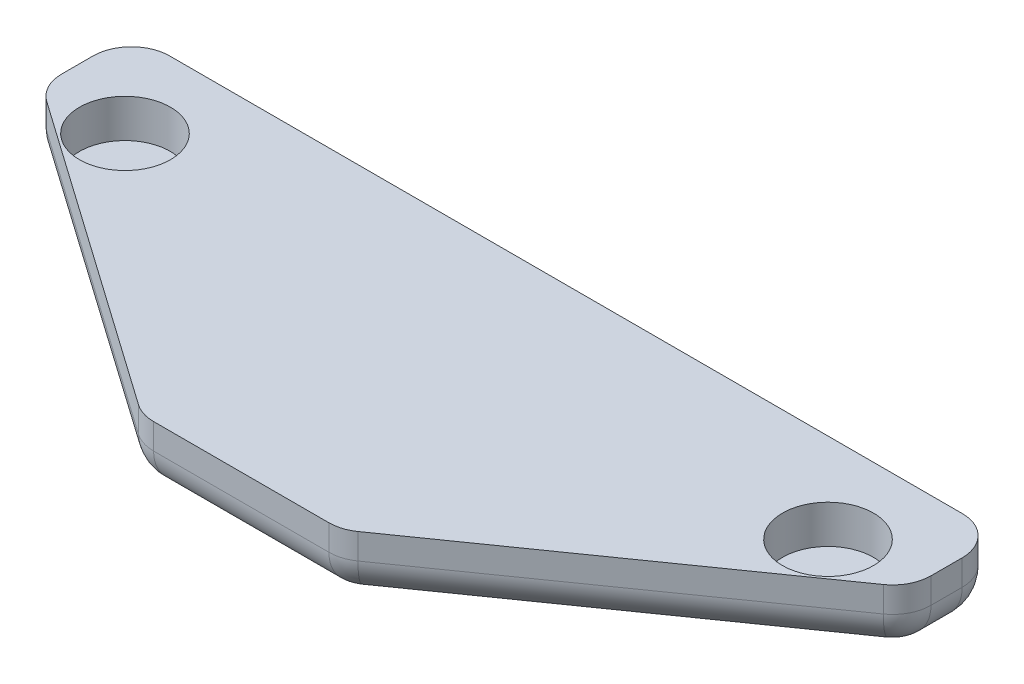
from build123d import *

# Parameters (mm, degrees)
BOSS_EXTRUDE1_DEPTH = 2.5
SKETCH2_R           = 1.78
CUT_EXTRUDE1_DEPTH  = 1.5
FILLET1_R           = 1.5


with BuildPart() as part:
    # Sketch1 → Boss-Extrude1 (new body)
    with BuildSketch(Plane(origin=(0, 0, 0), x_dir=(1, 0, 0), z_dir=(0, 1, 0))):
        Polygon((-21.216153836, 11.741903429), (-21.216153836, 8.241903429), (-8.120509951, -0.958096571), (-4.216153836, -0.958096571), (-4.216153836, 11.741903429), align=None)
    extrude(amount=BOSS_EXTRUDE1_DEPTH)

    # Sketch2 → Cut-Extrude1 (cut)
    with BuildSketch(Plane(origin=(0, 2.5, 0), x_dir=(1, 0, 0), z_dir=(0, 1, 0))):
        with Locations((-17.966153836, 8.241903429)):
            Circle(SKETCH2_R)
    extrude(amount=-CUT_EXTRUDE1_DEPTH, mode=Mode.SUBTRACT)

    # Fillet1
    fillet1_edges = [part.edges().sort_by_distance(p)[0] for p in [
        (-6.168331894, 0, 0.958096571),
        (-14.668331894, 0, -3.641903429),
        (-21.216153836, 0, -9.991903429),
        (-12.716153836, 0, -11.741903429),
        (-8.120509951, 1.25, 0.958096571),
        (-21.216153836, 1.25, -8.241903429),
        (-21.216153836, 1.25, -11.741903429),
    ]]
    fillet(fillet1_edges, radius=FILLET1_R)

    # Mirror1: part across plane


with BuildPart() as part_1:
    add(part.part)
    add(part.part.mirror(Plane(origin=(-4.216153836, 2.5, 0.958096571), x_dir=(0, 0, 1), z_dir=(-1, 0, 0))))


solid = part_1.part
